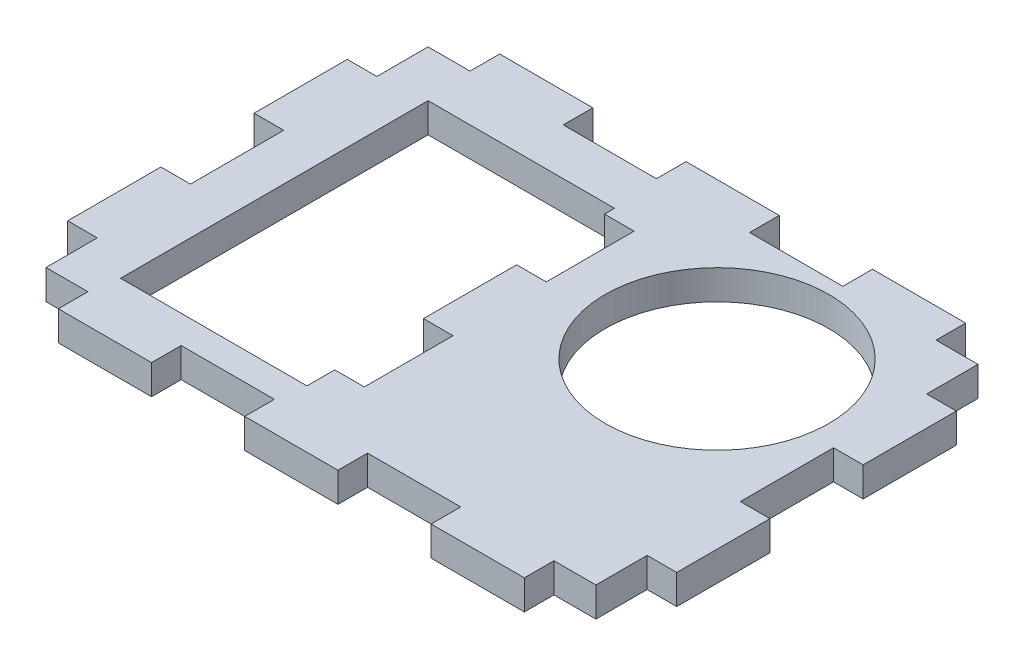
from build123d import *

# Parameters (mm, degrees)
SKETCH1_W           = 65.35
SKETCH1_H           = 47.35
SKETCH1_R           = 12
SKETCH1_W_2         = 20
SKETCH1_H_2         = 33
BOSS_EXTRUDE1_DEPTH = 3.175
SKETCH2_W           = 10
SKETCH2_H           = 3.175
SKETCH2_W_2         = 4.5
SKETCH2_W_3         = 3.175
SKETCH2_H_2         = 10
SKETCH2_H_3         = 5.5
SKETCH2_H_4         = 9.424306971
SKETCH2_H_5         = 9.524418783
CUT_EXTRUDE1_DEPTH  = 3.175


with BuildPart() as part:
    # Sketch1 → Boss-Extrude1 (new body)
    with BuildSketch(Plane(origin=(0, 0, 0), x_dir=(1, 0, 0), z_dir=(0, 1, 0))):
        with Locations((32.675, 23.675)):
            Rectangle(SKETCH1_W, SKETCH1_H)
        with Locations((47.675, 30.675)):
            Circle(SKETCH1_R, mode=Mode.SUBTRACT)
        with Locations((18.175, 22.675)):
            Rectangle(SKETCH1_W_2, SKETCH1_H_2, mode=Mode.SUBTRACT)
    extrude(amount=BOSS_EXTRUDE1_DEPTH)

    # Sketch2 → Cut-Extrude1 (cut)
    with BuildSketch(Plane(origin=(0, 3.175, 0), x_dir=(1, 0, 0), z_dir=(0, 1, 0))):
        with Locations((22.675, 45.7625)):
            Rectangle(SKETCH2_W, SKETCH2_H)
        with Locations((42.675, 45.7625)):
            Rectangle(SKETCH2_W, SKETCH2_H)
        with Locations((59.925, 45.7625)):
            Rectangle(SKETCH2_W_2, SKETCH2_H)
        Polygon((65.35, 47.35), (62.175, 47.35), (62.175, 44.175), (62.175, 38.675), (65.35, 38.675), align=None)
        with Locations((63.7625, 23.675)):
            Rectangle(SKETCH2_W_3, SKETCH2_H_2)
        Polygon((62.175, 3.175), (62.175, 0), (65.35, 0), (65.35, 8.675), (62.175, 8.675), align=None)
        with Locations((59.925, 1.5875)):
            Rectangle(SKETCH2_W_2, SKETCH2_H)
        with Locations((42.675, 1.5875)):
            Rectangle(SKETCH2_W, SKETCH2_H)
        with Locations((22.675, 1.5875)):
            Rectangle(SKETCH2_W, SKETCH2_H)
        with Locations((5.425, 1.5875)):
            Rectangle(SKETCH2_W_2, SKETCH2_H)
        Polygon((3.175, 3.175), (3.175, 8.675), (0, 8.675), (0, 0), (3.175, 0), align=None)
        with Locations((1.5875, 23.675)):
            Rectangle(SKETCH2_W_3, SKETCH2_H_2)
        with Locations((1.5875, 41.425)):
            Rectangle(SKETCH2_W_3, SKETCH2_H_3)
        with Locations((5.425, 45.7625)):
            Rectangle(SKETCH2_W_2, SKETCH2_H)
        with Locations((1.5875, 45.7625)):
            Rectangle(SKETCH2_W_3, SKETCH2_H)
        with Locations((29.7625, 33.387153486)):
            Rectangle(SKETCH2_W_3, SKETCH2_H_4)
        with Locations((29.7625, 13.912790608)):
            Rectangle(SKETCH2_W_3, SKETCH2_H_5)
    extrude(amount=-CUT_EXTRUDE1_DEPTH, mode=Mode.SUBTRACT)


solid = part.part
